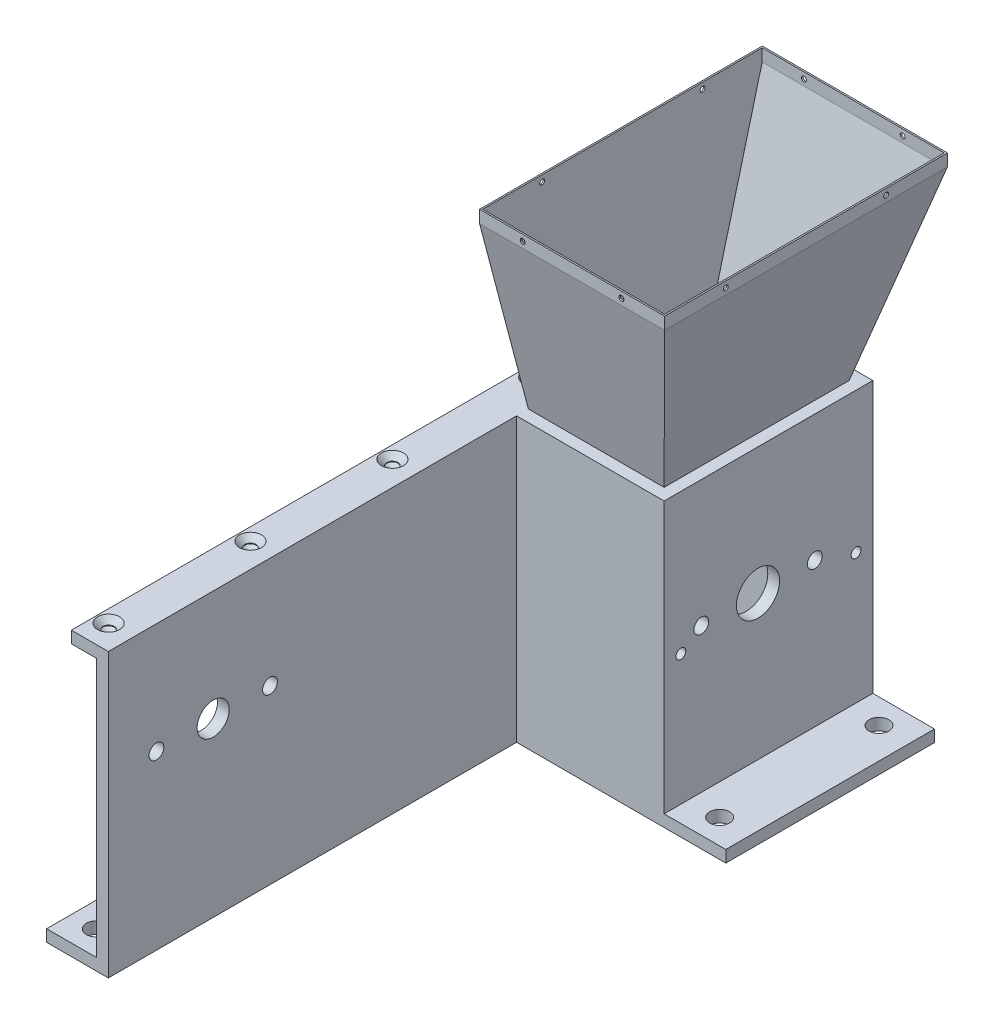
from build123d import *

# Parameters (mm, degrees)
BOSS_EXTRUDE1_DEPTH                 = 500
SKETCH2_W                           = 9.58
SKETCH2_H                           = 229.16
BOSS_EXTRUDE2_DEPTH                 = 110
SKETCH3_W                           = 9.58
SKETCH3_H                           = 229.16
BOSS_EXTRUDE3_DEPTH                 = 150
BOSS_EXTRUDE3_DEPTH_BACK            = 9.58
BOSS_EXTRUDE5_REACH                 = 162
SKETCH4_W                           = 9.58
SKETCH4_H                           = 229.16
BOSS_EXTRUDE5_DIRECTION_2_DEPTH     = 9.58
SKETCH5_W                           = 169.16
SKETCH5_H                           = 9.58
BOSS_EXTRUDE6_DEPTH                 = 50
SKETCH6_R                           = 8
CUT_EXTRUDE1_DEPTH                  = 10.58
SKETCH9_W                           = 110
SKETCH9_H                           = 150
SKETCH10_W                          = 150
SKETCH10_H                          = 229.16
SHELL1_T                            = -1.2
SKETCH13_W                          = 107.878066024
SKETCH13_H                          = 148.151135048
CUT_EXTRUDE2_DEPTH                  = 50
ESBO_O2_R                           = 6
ESBO_O2_R_2                         = 13
CORTE_EXTRUS_O2_DEPTH               = 51
ESBO_O3_R                           = 6
ESBO_O3_R_2                         = 12.5
CORTE_EXTRUS_O3_DEPTH               = 170.58
ESBO_O4_R                           = 17.5
CORTE_EXTRUS_O4_DEPTH               = 9.58
ESBO_O5_W                           = 110
ESBO_O5_H                           = 9.525
RESSALTO_EXTRUS_O1_DEPTH            = 45
ESBO_O6_W                           = 6
ESBO_O6_H                           = 18
CORTE_EXTRUS_O5_DEPTH               = 132.146995402
ESBO_O7_W                           = 110
ESBO_O7_H                           = 9.525
RESSALTO_EXTRUS_O2_DEPTH            = 30
FILETE1_R                           = 4.76
ESBO_O8_R                           = 5.4
CORTE_EXTRUS_O6_DEPTH               = 50.1050001
ESBO_O10_R                          = 4
CORTE_EXTRUS_O8_DEPTH               = 170.58
ESCAREADO_PARA_SFHCS_M81_AT_2_COUNT = 2
ESCAREADO_PARA_SFHCS_M81_AT_2_PITCH = 115
ESCAREADO_PARA_SFHCS_M81_AT_3_COUNT = 2
ESCAREADO_PARA_SFHCS_M81_AT_3_PITCH = 230
ESCAREADO_PARA_SFHCS_M81_AT_4_COUNT = 2
ESCAREADO_PARA_SFHCS_M81_AT_4_PITCH = 345
ESCAREADO_PARA_SFHCS_M81_AT_5_COUNT = 2
ESCAREADO_PARA_SFHCS_M81_AT_5_PITCH = 460
PADR_O_LINEAR1_COUNT                = 10
PADR_O_LINEAR1_PITCH                = 10
ESBO_O13_W                          = 150
ESBO_O13_H                          = 229.16
ESBO_O13_W_2                        = 147.558066024
ESBO_O13_H_2                        = 226.677855048
RESSALTO_EXTRUS_O3_DEPTH            = 10
ESBO_O14_R                          = 2
CORTE_EXTRUS_O9_DEPTH               = 201
ESBO_O15_R                          = 2
CORTE_EXTRUS_O10_DEPTH              = 531


with BuildPart() as part:
    # Sketch1 → Boss-Extrude1 (new body)
    with BuildSketch(Plane.XY):
        Polygon((0, 0), (50, 0), (50, 229.16), (20, 229.16), (20, 219.58), (40.42, 219.58), (40.42, 9.58), (0, 9.58), align=None)
    extrude(amount=BOSS_EXTRUDE1_DEPTH)

    # Sketch2 → Boss-Extrude2 (add)
    with BuildSketch(Plane(origin=(50, 0, 0), x_dir=(0, 0, -1), z_dir=(1, 0, 0))):
        with Locations((-4.79, 114.58)):
            Rectangle(SKETCH2_W, SKETCH2_H)
    extrude(amount=BOSS_EXTRUDE2_DEPTH)

    # Sketch3 → Boss-Extrude3 (add, two sides)
    with BuildSketch(Plane.XY.offset(9.58)) as boss_extrude3_sk:
        with Locations((164.79, 114.58)):
            Rectangle(SKETCH3_W, SKETCH3_H)
    extrude(amount=BOSS_EXTRUDE3_DEPTH)
    extrude(boss_extrude3_sk.sketch, amount=-BOSS_EXTRUDE3_DEPTH_BACK)

    # Sketch4 → Boss-Extrude5 (add, up to next)
    with BuildSketch(Plane.ZY.offset(-160), mode=Mode.PRIVATE) as boss_extrude5_sk1:
        with Locations((164.37, 114.58)):
            Rectangle(SKETCH4_W, SKETCH4_H)
    boss_extrude5_tool1 = extrude(boss_extrude5_sk1.sketch, amount=BOSS_EXTRUDE5_REACH, mode=Mode.PRIVATE) - part.part
    add(boss_extrude5_tool1.solids().sort_by_distance((160, 114.58, 164.37))[0])

    # Sketch4 → Boss-Extrude5 direction 2 (add)
    with BuildSketch(Plane.ZY.offset(-160)):
        with Locations((164.37, 114.58)):
            Rectangle(SKETCH4_W, SKETCH4_H)
    extrude(amount=-BOSS_EXTRUDE5_DIRECTION_2_DEPTH)

    # Sketch5 → Boss-Extrude6 (add)
    with BuildSketch(Plane(origin=(169.58, 0, 0), x_dir=(0, 0, -1), z_dir=(1, 0, 0))):
        with Locations((-84.58, 4.79)):
            Rectangle(SKETCH5_W, SKETCH5_H)
    extrude(amount=BOSS_EXTRUDE6_DEPTH)

    # Sketch6 → Cut-Extrude1 (cut, through all)
    with BuildSketch(Plane(origin=(0, 9.58, 0), x_dir=(-1, 0, 0), z_dir=(0, 1, 0))):
        with Locations((-194.58, 149.16)):
            Circle(SKETCH6_R)
        with Locations((-194.58, 20)):
            Circle(SKETCH6_R)
        with Locations((-20.21, 480)):
            Circle(SKETCH6_R)
        with Locations((-20.21, 20)):
            Circle(SKETCH6_R)
        with Locations((-20.21, 250)):
            Circle(SKETCH6_R)
    extrude(amount=-CUT_EXTRUDE1_DEPTH, mode=Mode.SUBTRACT)

    # Esbo_o2 → Corte-extrus_o2 (cut, through all)
    with BuildSketch(Plane(origin=(50, 0, 0), x_dir=(0, 0, -1), z_dir=(1, 0, 0))):
        with Locations((-461, 139.58)):
            Circle(ESBO_O2_R)
        with Locations((-369, 139.58)):
            Circle(ESBO_O2_R)
        with Locations((-415, 139.58)):
            Circle(ESBO_O2_R_2)
    extrude(amount=-CORTE_EXTRUS_O2_DEPTH, mode=Mode.SUBTRACT)

    # Esbo_o3 → Corte-extrus_o3 (cut, through all)
    with BuildSketch(Plane(origin=(169.58, 0, 0), x_dir=(0, 0, -1), z_dir=(1, 0, 0))):
        with Locations((-139, 126.58)):
            Circle(ESBO_O3_R)
        with Locations((-47, 126.58)):
            Circle(ESBO_O3_R)
        with Locations((-93.04216577, 126.384495402)):
            Circle(ESBO_O3_R_2)
    extrude(amount=-CORTE_EXTRUS_O3_DEPTH, mode=Mode.SUBTRACT)

    # Esbo_o4 → Corte-extrus_o4 (cut)
    with BuildSketch(Plane(origin=(169.58, 0, 0), x_dir=(0, 0, -1), z_dir=(1, 0, 0))):
        with Locations((-93.04216577, 126.384495402)):
            Circle(ESBO_O4_R)
    extrude(amount=-CORTE_EXTRUS_O4_DEPTH, mode=Mode.SUBTRACT)

    # Esbo_o5 → Ressalto-extrus_o1 (add)
    with BuildSketch(Plane.XY.offset(9.58)):
        with Locations((105, 126.384495402)):
            Rectangle(ESBO_O5_W, ESBO_O5_H)
    extrude(amount=RESSALTO_EXTRUS_O1_DEPTH)

    # Esbo_o6 → Corte-extrus_o5 (cut, through all)
    with BuildSketch(Plane(origin=(0, 131.146995402, 0), x_dir=(1, 0, 0), z_dir=(0, 1, 0))):
        with Locations((57.65, -45.58)):
            Rectangle(ESBO_O6_W, ESBO_O6_H)
    corte_extrus_o5 = extrude(amount=-CORTE_EXTRUS_O5_DEPTH, mode=Mode.SUBTRACT)

    # Esbo_o7 → Ressalto-extrus_o2 (add)
    with BuildSketch(Plane(origin=(0, 131.146995402, 0), x_dir=(1, 0, 0), z_dir=(0, 1, 0))):
        with Locations((105, -14.3425)):
            Rectangle(ESBO_O7_W, ESBO_O7_H)
    extrude(amount=RESSALTO_EXTRUS_O2_DEPTH)

    # Filete1
    filete1_edges = [part.edges().sort_by_distance(p)[0] for p in [
        (105, 131.146995402, 19.105),
    ]]
    fillet(filete1_edges, radius=FILETE1_R)

    # Esbo_o8 → Corte-extrus_o6 (cut, through all)
    with BuildSketch(Plane.XY.offset(19.105)):
        with Locations((105, 148.526995402)):
            Circle(ESBO_O8_R)
        with Locations((145, 148.526995402)):
            Circle(ESBO_O8_R)
        with Locations((65, 148.526995402)):
            Circle(ESBO_O8_R)
    extrude(amount=-CORTE_EXTRUS_O6_DEPTH, mode=Mode.SUBTRACT)

    # Esbo_o10 → Corte-extrus_o8 (cut, through all)
    with BuildSketch(Plane(origin=(169.58, 0, 0), x_dir=(0, 0, -1), z_dir=(1, 0, 0))):
        with Locations((-155.58, 115.16)):
            Circle(ESBO_O10_R)
        with Locations((-13.58, 115.16)):
            Circle(ESBO_O10_R)
    extrude(amount=-CORTE_EXTRUS_O8_DEPTH, mode=Mode.SUBTRACT)

    # Esbo_o11 → Escareado para SFHCS M81 (revolve, cut)
    with BuildSketch(Plane(origin=(30.21, 229.16, 20), x_dir=(0, 0, 1), z_dir=(1, 0, 0))):
        Polygon((0, 0), (0, 7.703872786), (4.5, 5), (4.5, 4.46), (8.96, 0), align=None)
    escareado_para_sfhcs_m81 = revolve(axis=Axis((30.21, 235.51, 20), (0, -1, 0)), mode=Mode.SUBTRACT)

    # Escareado para SFHCS M81 at 2: Escareado para SFHCS M81 ×2
    with Locations(*[(0, 0, i * ESCAREADO_PARA_SFHCS_M81_AT_2_PITCH) for i in range(1, ESCAREADO_PARA_SFHCS_M81_AT_2_COUNT)]):
        add(escareado_para_sfhcs_m81, mode=Mode.SUBTRACT)

    # Escareado para SFHCS M81 at 3: Escareado para SFHCS M81 ×2
    with Locations(*[(0, 0, i * ESCAREADO_PARA_SFHCS_M81_AT_3_PITCH) for i in range(1, ESCAREADO_PARA_SFHCS_M81_AT_3_COUNT)]):
        add(escareado_para_sfhcs_m81, mode=Mode.SUBTRACT)

    # Escareado para SFHCS M81 at 4: Escareado para SFHCS M81 ×2
    with Locations(*[(0, 0, i * ESCAREADO_PARA_SFHCS_M81_AT_4_PITCH) for i in range(1, ESCAREADO_PARA_SFHCS_M81_AT_4_COUNT)]):
        add(escareado_para_sfhcs_m81, mode=Mode.SUBTRACT)

    # Escareado para SFHCS M81 at 5: Escareado para SFHCS M81 ×2
    with Locations(*[(0, 0, i * ESCAREADO_PARA_SFHCS_M81_AT_5_PITCH) for i in range(1, ESCAREADO_PARA_SFHCS_M81_AT_5_COUNT)]):
        add(escareado_para_sfhcs_m81, mode=Mode.SUBTRACT)

    # Padr_o linear1: Corte-extrus_o5 ×10
    with Locations(*[(i * PADR_O_LINEAR1_PITCH, 0, 0) for i in range(1, PADR_O_LINEAR1_COUNT)]):
        add(corte_extrus_o5, mode=Mode.SUBTRACT)


with BuildPart() as body_2:
    # Sketch9 → Loft1 section 0
    with BuildSketch(Plane(origin=(0, 229.16, 0), x_dir=(1, 0, 0), z_dir=(0, 1, 0))):
        with Locations((105, -84.58)):
            Rectangle(SKETCH9_W, SKETCH9_H)
    # Sketch10 → Loft1 section 1
    with BuildSketch(Plane(origin=(0, 379.16, 0), x_dir=(-1, 0, 0), z_dir=(0, 1, 0))):
        with Locations((-125, 84.58)):
            Rectangle(SKETCH10_W, SKETCH10_H)
    loft()

    # Shell1
    shell1_openings = [body_2.faces().sort_by_distance(p)[0] for p in [
        (125, 379.16, 84.58),
    ]]
    offset(amount=SHELL1_T, openings=shell1_openings, kind=Kind.INTERSECTION)

    # Sketch13 → Cut-Extrude2 (cut)
    with BuildSketch(Plane(origin=(0, 230.36, 0), x_dir=(1, 0, 0), z_dir=(0, 1, 0))):
        with Locations((105.139033012, -84.58)):
            Rectangle(SKETCH13_W, SKETCH13_H)
    extrude(amount=-CUT_EXTRUDE2_DEPTH, mode=Mode.SUBTRACT)

    # Esbo_o13 → Ressalto-extrus_o3 (add)
    with BuildSketch(Plane(origin=(0, 379.16, 0), x_dir=(1, 0, 0), z_dir=(0, 1, 0))):
        with Locations((125, -84.58)):
            Rectangle(ESBO_O13_W, ESBO_O13_H)
        with Locations((124.979033012, -84.58)):
            Rectangle(ESBO_O13_W_2, ESBO_O13_H_2, mode=Mode.SUBTRACT)
    extrude(amount=RESSALTO_EXTRUS_O3_DEPTH)

    # Esbo_o14 → Corte-extrus_o9 (cut, through all)
    with BuildSketch(Plane(origin=(200, 0, 0), x_dir=(0, 0, -1), z_dir=(1, 0, 0))):
        with Locations((-149.58, 384.16)):
            Circle(ESBO_O14_R)
        with Locations((-19.58, 384.16)):
            Circle(ESBO_O14_R)
    extrude(amount=-CORTE_EXTRUS_O9_DEPTH, mode=Mode.SUBTRACT)

    # Esbo_o15 → Corte-extrus_o10 (cut, through all)
    with BuildSketch(Plane(origin=(0, 0, -30), x_dir=(-1, 0, 0), z_dir=(0, 0, -1))):
        with Locations((-85, 384.16)):
            Circle(ESBO_O15_R)
        with Locations((-165, 384.16)):
            Circle(ESBO_O15_R)
    extrude(amount=-CORTE_EXTRUS_O10_DEPTH, mode=Mode.SUBTRACT)


solid = Compound([part.part, body_2.part])
